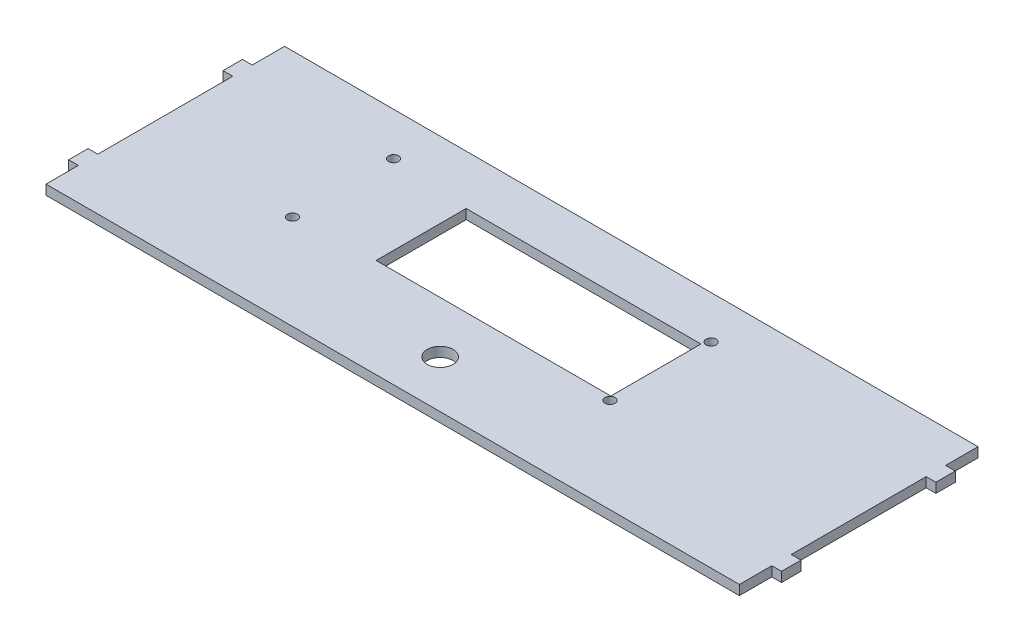
from build123d import *

# Parameters (mm, degrees)
CROQUIS1_W              = 214
CROQUIS1_H              = 73.64
SALIENTE_EXTRUIR1_DEPTH = 3
CROQUIS3_W              = 3
CROQUIS3_H              = 6
SALIENTE_EXTRUIR2_DEPTH = 3
CROQUIS2_R              = 4
CORTAR_EXTRUIR1_DEPTH   = 4
CROQUIS5_R              = 1.55
CORTAR_EXTRUIR3_DEPTH   = 4
CROQUIS6_W              = 72.45
CROQUIS6_H              = 27.8
CORTAR_EXTRUIR4_DEPTH   = 4


with BuildPart() as part:
    # Croquis1 → Saliente-Extruir1 (new body)
    with BuildSketch(Plane(origin=(0, 0, 0), x_dir=(1, 0, 0), z_dir=(0, 1, 0))):
        Rectangle(CROQUIS1_W, CROQUIS1_H)
    extrude(amount=SALIENTE_EXTRUIR1_DEPTH)

    # Croquis3 → Saliente-Extruir2 (add, through all)
    with BuildSketch(Plane(origin=(0, 3, 0), x_dir=(1, 0, 0), z_dir=(0, 1, 0))):
        with Locations((-108.5, 23.82)):
            Rectangle(CROQUIS3_W, CROQUIS3_H)
        with Locations((-108.5, -23.82)):
            Rectangle(CROQUIS3_W, CROQUIS3_H)
        with Locations((108.5, 23.82)):
            Rectangle(CROQUIS3_W, CROQUIS3_H)
        with Locations((108.5, -23.82)):
            Rectangle(CROQUIS3_W, CROQUIS3_H)
    extrude(amount=-SALIENTE_EXTRUIR2_DEPTH)

    # Croquis2 → Cortar-Extruir1 (cut, through all)
    with BuildSketch(Plane(origin=(0, 3, 0), x_dir=(1, 0, 0), z_dir=(0, 1, 0))):
        with Locations((0, -22.18)):
            Circle(CROQUIS2_R)
    extrude(amount=-CORTAR_EXTRUIR1_DEPTH, mode=Mode.SUBTRACT)

    # Croquis5 → Cortar-Extruir3 (cut, through all)
    with BuildSketch(Plane(origin=(0, 3, 0), x_dir=(1, 0, 0), z_dir=(0, 1, 0))):
        with Locations((-60.15, 23.604994207)):
            Circle(CROQUIS5_R)
        with Locations((37.85, 23.604994207)):
            Circle(CROQUIS5_R)
        with Locations((37.85, -7.595005793)):
            Circle(CROQUIS5_R)
        with Locations((-60.15, -7.595005793)):
            Circle(CROQUIS5_R)
    extrude(amount=-CORTAR_EXTRUIR3_DEPTH, mode=Mode.SUBTRACT)

    # Croquis6 → Cortar-Extruir4 (cut, through all)
    with BuildSketch(Plane(origin=(0, 3, 0), x_dir=(1, 0, 0), z_dir=(0, 1, 0))):
        with Locations((0.575, 7.604994207)):
            Rectangle(CROQUIS6_W, CROQUIS6_H)
    extrude(amount=-CORTAR_EXTRUIR4_DEPTH, mode=Mode.SUBTRACT)


solid = part.part
